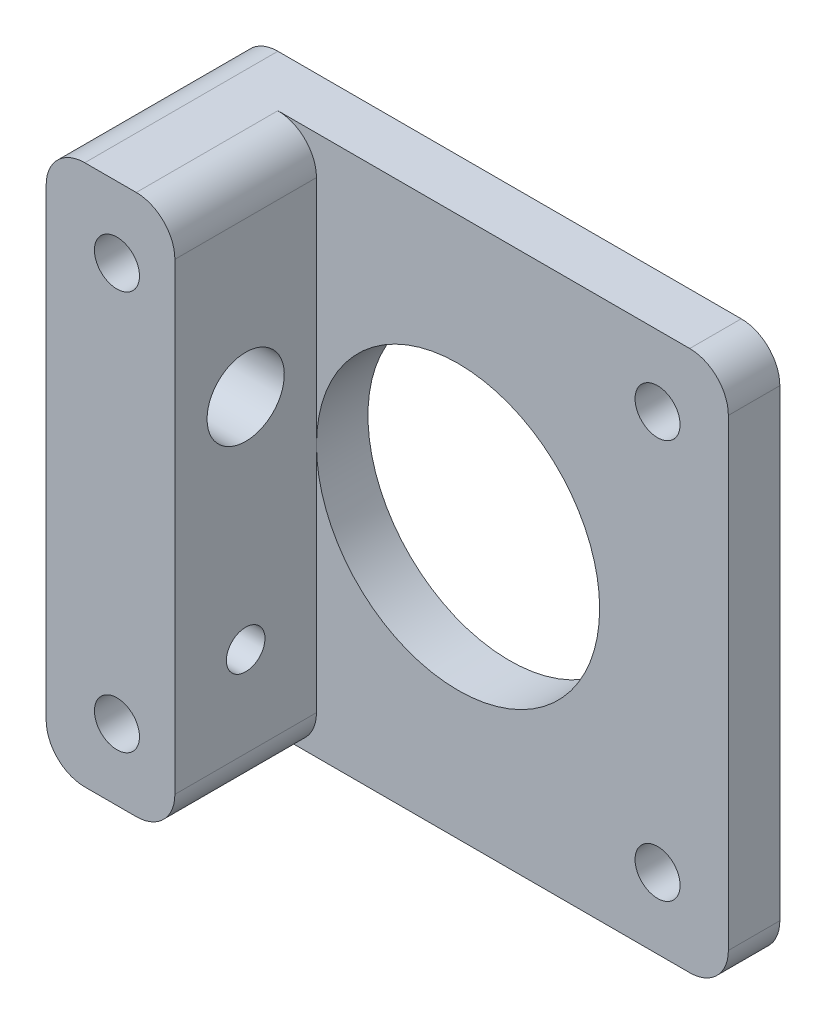
from build123d import *

# Parameters (mm, degrees)
SKETCH1_W           = 42
SKETCH1_H           = 42
BOSS_EXTRUDE1_DEPTH = 4
SKETCH2_W           = 10
SKETCH2_H           = 42
BOSS_EXTRUDE2_DEPTH = 11
SKETCH3_R           = 11
CUT_EXTRUDE1_DEPTH  = 11
FILLET1_R           = 3
SKETCH4_R           = 1.75
CUT_EXTRUDE2_DEPTH  = 21
SKETCH6_R           = 3
SKETCH6_R_2         = 1.5
CUT_EXTRUDE3_DEPTH  = 21


with BuildPart() as part:
    # Sketch1 → Boss-Extrude1 (new body)
    with BuildSketch(Plane.XY):
        Rectangle(SKETCH1_W, SKETCH1_H)
    extrude(amount=BOSS_EXTRUDE1_DEPTH)

    # Sketch2 → Boss-Extrude2 (add)
    with BuildSketch(Plane.XY.offset(4)):
        with Locations((-16, 0)):
            Rectangle(SKETCH2_W, SKETCH2_H)
    extrude(amount=BOSS_EXTRUDE2_DEPTH)

    # Sketch3 → Cut-Extrude1 (cut)
    with BuildSketch(Plane.XY.offset(4)):
        Circle(SKETCH3_R)
    extrude(amount=-CUT_EXTRUDE1_DEPTH, mode=Mode.SUBTRACT)

    # Fillet1
    fillet1_edges = [part.edges().sort_by_distance(p)[0] for p in [
        (-11, -21, 9.5),
        (-11, 21, 9.5),
        (21, -21, 2),
        (-21, -21, 7.5),
        (-21, 21, 7.5),
        (21, 21, 2),
    ]]
    fillet(fillet1_edges, radius=FILLET1_R)

    # Sketch4 → Cut-Extrude2 (cut)
    with BuildSketch(Plane.XY.offset(15)):
        with Locations((-15.5, 15.5)):
            Circle(SKETCH4_R)
        with Locations((-15.5, -15.5)):
            Circle(SKETCH4_R)
        with Locations((15.5, 15.5)):
            Circle(SKETCH4_R)
        with Locations((15.5, -15.5)):
            Circle(SKETCH4_R)
    extrude(amount=-CUT_EXTRUDE2_DEPTH, mode=Mode.SUBTRACT)

    # Sketch6 → Cut-Extrude3 (cut)
    with BuildSketch(Plane.ZY.offset(21)):
        with Locations((9.5, 6)):
            Circle(SKETCH6_R)
        with Locations((9.5, -11)):
            Circle(SKETCH6_R_2)
    extrude(amount=-CUT_EXTRUDE3_DEPTH, mode=Mode.SUBTRACT)


solid = part.part
